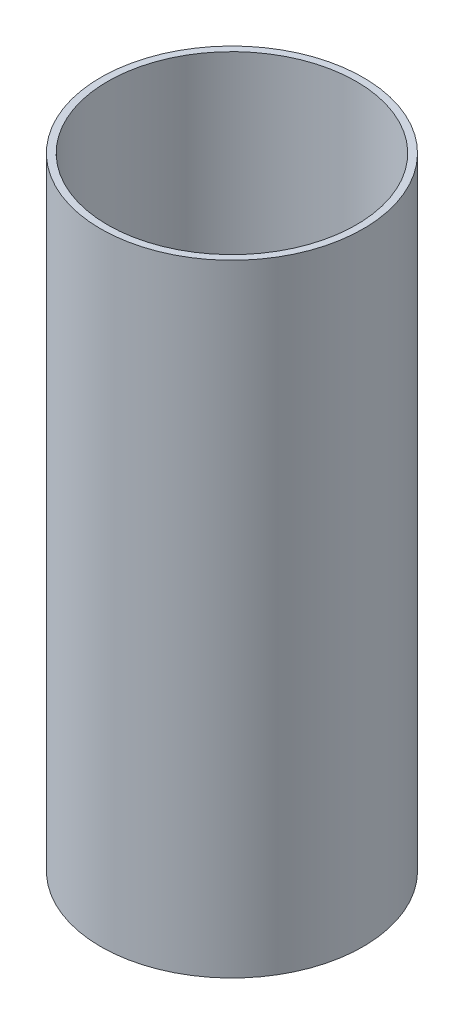
from build123d import *

# Parameters (mm, degrees)
SKETCH1_R           = 19
SKETCH1_R_2         = 8
SKETCH1_R_3         = 2.5
BOSS_EXTRUDE1_DEPTH = 3
SKETCH1_5_R         = 19
SKETCH1_5_R_2       = 18
BOSS_EXTRUDE2_DEPTH = 90
SKETCH2_R           = 5.25
CUT_EXTRUDE1_DEPTH  = 94.925502394


with BuildPart() as part:
    # Sketch1 → Boss-Extrude1 (new body)
    with BuildSketch(Plane(origin=(0, 0, 0), x_dir=(1, 0, 0), z_dir=(0, 1, 0))):
        Circle(SKETCH1_R)
        Circle(SKETCH1_R_2, mode=Mode.SUBTRACT)
        with Locations((-13.05625, 0)):
            Circle(SKETCH1_R_3, mode=Mode.SUBTRACT)
    extrude(amount=BOSS_EXTRUDE1_DEPTH)

    # Sketch1_5 → Boss-Extrude2 (add)
    with BuildSketch(Plane(origin=(0, 0, 0), x_dir=(1, 0, 0), z_dir=(0, 1, 0))):
        Circle(SKETCH1_5_R)
        Circle(SKETCH1_5_R_2, mode=Mode.SUBTRACT)
    extrude(amount=BOSS_EXTRUDE2_DEPTH)

    # Sketch2 → Cut-Extrude1 (cut, through all)
    with BuildSketch(Plane(origin=(0, 0, 0), x_dir=(0, 0, -1), z_dir=(1, 0, 0))):
        with Locations((0, 17)):
            Circle(SKETCH2_R)
    extrude(amount=-CUT_EXTRUDE1_DEPTH, mode=Mode.SUBTRACT)


solid = part.part
